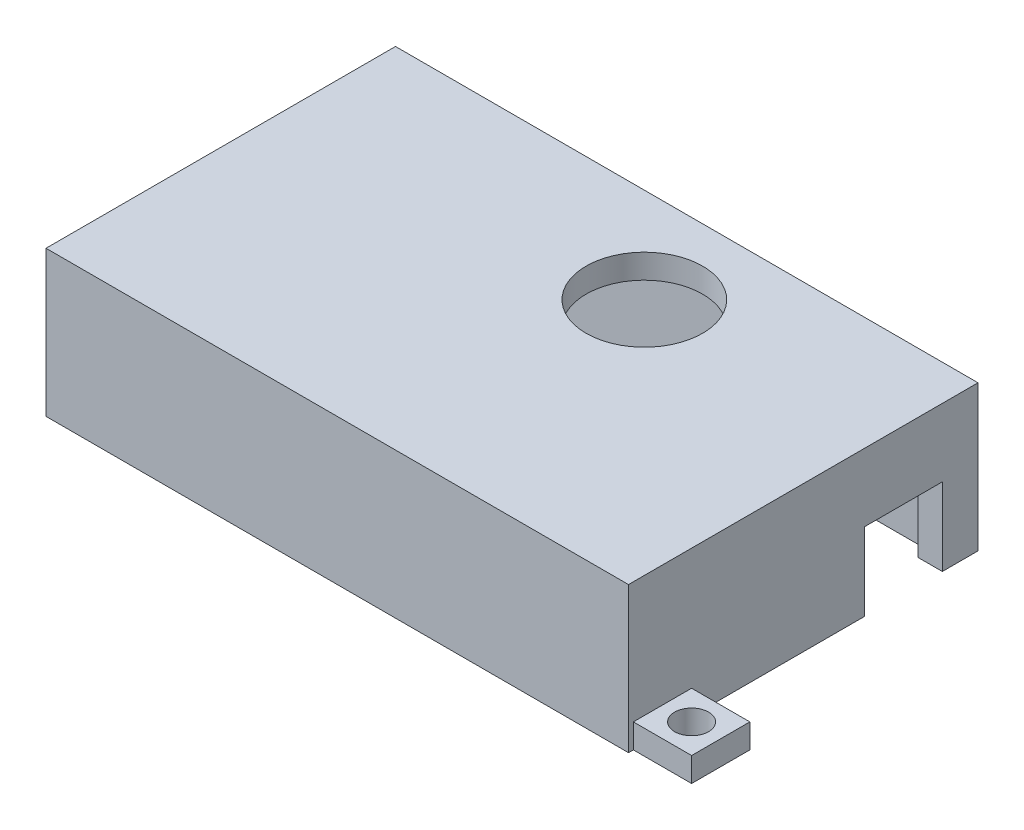
from build123d import *

# Parameters (mm, degrees)
SKETCH2_W           = 60
SKETCH2_H           = 36
BOSS_EXTRUDE2_DEPTH = 15
SKETCH5_W           = 55
SKETCH5_H           = 31
CUT_EXTRUDE1_DEPTH  = 12.5
SKETCH6_W           = 6
SKETCH6_H           = 6
SKETCH6_R           = 1.75
BOSS_EXTRUDE3_DEPTH = 2.5
SKETCH7_R           = 6
CUT_EXTRUDE2_DEPTH  = 15
BOSS_EXTRUDE4_DEPTH = 12.5
SKETCH10_W          = 8
SKETCH10_H          = 8
CUT_EXTRUDE3_DEPTH  = 12.5


with BuildPart() as part:
    # Sketch2 → Boss-Extrude2 (new body)
    with BuildSketch(Plane(origin=(0, 0, 0), x_dir=(1, 0, 0), z_dir=(0, 1, 0))):
        Rectangle(SKETCH2_W, SKETCH2_H)
    extrude(amount=BOSS_EXTRUDE2_DEPTH)

    # Sketch5 → Cut-Extrude1 (cut)
    with BuildSketch(Plane(origin=(0, 0, 0), x_dir=(1, 0, 0), z_dir=(0, 1, 0))):
        Rectangle(SKETCH5_W, SKETCH5_H)
    extrude(amount=CUT_EXTRUDE1_DEPTH, mode=Mode.SUBTRACT)

    # Sketch6 → Boss-Extrude3 (add)
    with BuildSketch(Plane(origin=(0, 0, 0), x_dir=(1, 0, 0), z_dir=(0, 1, 0))):
        with Locations((-33, 15)):
            Rectangle(SKETCH6_W, SKETCH6_H)
        with Locations(Location((-33, 15, 0), (0, 0, 270))):  # turned: the seam where the file's is
            Circle(SKETCH6_R, mode=Mode.SUBTRACT)
        with Locations((33, -14.5)):
            Rectangle(SKETCH6_W, SKETCH6_H)
        with Locations(Location((33, -14.5, 0), (0, 0, 270))):  # turned: the seam where the file's is
            Circle(SKETCH6_R, mode=Mode.SUBTRACT)
    extrude(amount=BOSS_EXTRUDE3_DEPTH)

    # Sketch7 → Cut-Extrude2 (cut)
    with BuildSketch(Plane(origin=(0, 0, 0), x_dir=(1, 0, 0), z_dir=(0, 1, 0))):
        with Locations(Location((5.404735112, 8.226712099, 0), (0, 0, 270))):  # turned: the seam where the file's is
            Circle(SKETCH7_R)
    extrude(amount=CUT_EXTRUDE2_DEPTH, mode=Mode.SUBTRACT)

    # Sketch8 → Boss-Extrude4 (add)
    with BuildSketch(Plane(origin=(0, 0, 0), x_dir=(1, 0, 0), z_dir=(0, 1, 0))):
        Polygon((-21.035533906, 0), (-17.5, 0), (-17.5, 2.5), (-14.447985549, 2.5), (-14.447985549, 6.535533906), (-21.035533906, 6.535533906), align=None)
    extrude(amount=BOSS_EXTRUDE4_DEPTH)

    # Sketch10 → Cut-Extrude3 (cut)
    with BuildSketch(Plane(origin=(30, 0, 0), x_dir=(0, 0, -1), z_dir=(1, 0, 0))):
        with Locations((10.327095022, 4)):
            Rectangle(SKETCH10_W, SKETCH10_H)
    extrude(amount=-CUT_EXTRUDE3_DEPTH, mode=Mode.SUBTRACT)


solid = part.part
